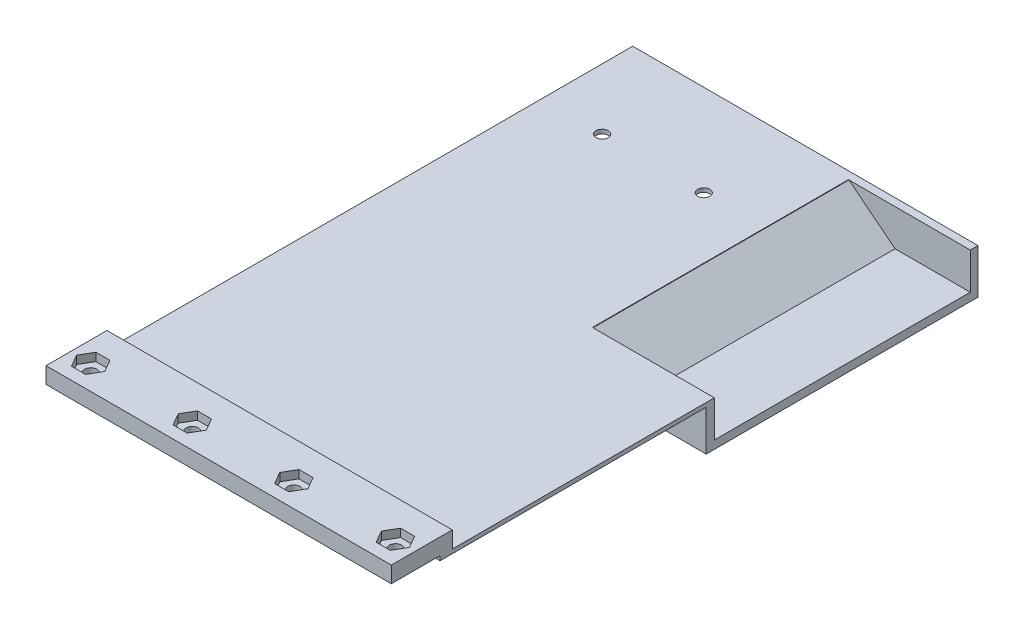
from build123d import *

# Parameters (mm, degrees)
SKETCH1_W           = 85
SKETCH1_H           = 12
SKETCH1_R           = 1.5
BOSS_EXTRUDE1_DEPTH = 2
SKETCH1_3_W         = 85
SKETCH1_3_H         = 12
BOSS_EXTRUDE2_DEPTH = 4
SKETCH2_W           = 85
SKETCH2_H           = 3
BOSS_EXTRUDE3_DEPTH = 5.1
BOSS_EXTRUDE4_DEPTH = 1
BOSS_EXTRUDE5_DEPTH = 10
SKETCH5_W           = 32
SKETCH5_H           = 67
BOSS_EXTRUDE6_DEPTH = 2
SKETCH6_W           = 32
SKETCH6_H           = 2
BOSS_EXTRUDE7_DEPTH = 11
BOSS_EXTRUDE9_DEPTH = 65
SKETCH9_W           = 100.016978449
SKETCH9_H           = 38.136204689
CUT_EXTRUDE1_DEPTH  = 0.1
SKETCH10_R          = 1.5
CUT_EXTRUDE2_DEPTH  = 6.1


with BuildPart() as part:
    # Sketch1 → Boss-Extrude1 (new body)
    with BuildSketch(Plane(origin=(0, 0, 0), x_dir=(1, 0, 0), z_dir=(0, 1, 0))):
        with Locations((42.5, 6)):
            Rectangle(SKETCH1_W, SKETCH1_H)
        Polygon((81.732050808, 3), (83.464101615, 6), (81.732050808, 9), (78.267949192, 9), (76.535898385, 6), (78.267949192, 3), align=None, mode=Mode.SUBTRACT)
        Polygon((56.732050808, 3), (58.464101615, 6), (56.732050808, 9), (53.267949192, 9), (51.535898385, 6), (53.267949192, 3), align=None, mode=Mode.SUBTRACT)
        Polygon((31.732050808, 3), (33.464101615, 6), (31.732050808, 9), (28.267949192, 9), (26.535898385, 6), (28.267949192, 3), align=None, mode=Mode.SUBTRACT)
        Polygon((6.732050808, 3), (8.464101615, 6), (6.732050808, 9), (3.267949192, 9), (1.535898385, 6), (3.267949192, 3), align=None, mode=Mode.SUBTRACT)
        Polygon((3.267949192, 3), (6.732050808, 3), (8.464101615, 6), (6.732050808, 9), (3.267949192, 9), (1.535898385, 6), align=None)
        with Locations((5, 6)):
            Circle(SKETCH1_R, mode=Mode.SUBTRACT)
        Polygon((28.267949192, 3), (31.732050808, 3), (33.464101615, 6), (31.732050808, 9), (28.267949192, 9), (26.535898385, 6), align=None)
        with Locations((30, 6)):
            Circle(SKETCH1_R, mode=Mode.SUBTRACT)
        Polygon((53.267949192, 3), (56.732050808, 3), (58.464101615, 6), (56.732050808, 9), (53.267949192, 9), (51.535898385, 6), align=None)
        with Locations((55, 6)):
            Circle(SKETCH1_R, mode=Mode.SUBTRACT)
        Polygon((78.267949192, 3), (81.732050808, 3), (83.464101615, 6), (81.732050808, 9), (78.267949192, 9), (76.535898385, 6), align=None)
        with Locations((80, 6)):
            Circle(SKETCH1_R, mode=Mode.SUBTRACT)
    extrude(amount=BOSS_EXTRUDE1_DEPTH)

    # Sketch1_3 → Boss-Extrude2 (add)
    with BuildSketch(Plane(origin=(0, 0, 0), x_dir=(1, 0, 0), z_dir=(0, 1, 0))):
        with Locations((42.5, 6)):
            Rectangle(SKETCH1_3_W, SKETCH1_3_H)
        Polygon((81.732050808, 3), (83.464101615, 6), (81.732050808, 9), (78.267949192, 9), (76.535898385, 6), (78.267949192, 3), align=None, mode=Mode.SUBTRACT)
        Polygon((56.732050808, 3), (58.464101615, 6), (56.732050808, 9), (53.267949192, 9), (51.535898385, 6), (53.267949192, 3), align=None, mode=Mode.SUBTRACT)
        Polygon((31.732050808, 3), (33.464101615, 6), (31.732050808, 9), (28.267949192, 9), (26.535898385, 6), (28.267949192, 3), align=None, mode=Mode.SUBTRACT)
        Polygon((6.732050808, 3), (8.464101615, 6), (6.732050808, 9), (3.267949192, 9), (1.535898385, 6), (3.267949192, 3), align=None, mode=Mode.SUBTRACT)
    extrude(amount=BOSS_EXTRUDE2_DEPTH)

    # Sketch2 → Boss-Extrude3 (add)
    with BuildSketch(Plane(origin=(0, 4, 0), x_dir=(1, 0, 0), z_dir=(0, 1, 0))):
        with Locations((42.5, 13.5)):
            Rectangle(SKETCH2_W, SKETCH2_H)
    extrude(amount=-BOSS_EXTRUDE3_DEPTH)

    # Sketch3 → Boss-Extrude4 (add)
    with BuildSketch(Plane.XZ.offset(1.1)):
        Polygon((85, -12), (0, -12), (0, -144.5), (55, -144.5), (55, -79.5), (85, -79.5), align=None)
    extrude(amount=-BOSS_EXTRUDE4_DEPTH)

    # Sketch4 → Boss-Extrude5 (add)
    with BuildSketch(Plane.XZ.offset(1.1)):
        Polygon((85, -79.5), (85, -77.5), (53, -77.5), (53, -144.5), (55, -144.5), (55, -79.5), align=None)
    extrude(amount=BOSS_EXTRUDE5_DEPTH)

    # Sketch5 → Boss-Extrude6 (add)
    with BuildSketch(Plane.XZ.offset(11.1)):
        with Locations((69, -111)):
            Rectangle(SKETCH5_W, SKETCH5_H)
    extrude(amount=-BOSS_EXTRUDE6_DEPTH)

    # Sketch6 → Boss-Extrude7 (add)
    with BuildSketch(Plane.XZ.offset(11.1)):
        with Locations((69, -143.5)):
            Rectangle(SKETCH6_W, SKETCH6_H)
    extrude(amount=-BOSS_EXTRUDE7_DEPTH)

    # Sketch8 → Boss-Extrude9 (add)
    with BuildSketch(Plane(origin=(0, 0, -144.5), x_dir=(-1, 0, 0), z_dir=(0, 0, -1))):
        Polygon((-55.130583843, -11.1), (-55.130583843, -0.1), (-69, -11.1), align=None)
    extrude(amount=-BOSS_EXTRUDE9_DEPTH)

    # Sketch9 → Cut-Extrude1 (cut)
    with BuildSketch(Plane(origin=(0, 0, -144.5), x_dir=(-1, 0, 0), z_dir=(0, 0, -1))):
        with Locations((-50.008489225, -19.168102345)):
            Rectangle(SKETCH9_W, SKETCH9_H)
    extrude(amount=-CUT_EXTRUDE1_DEPTH, mode=Mode.SUBTRACT)

    # Sketch10 → Cut-Extrude2 (cut, through all)
    with BuildSketch(Plane.XZ.offset(1.1)):
        with Locations((15, -121.9)):
            Circle(SKETCH10_R)
        with Locations((40, -121.9)):
            Circle(SKETCH10_R)
    extrude(amount=-CUT_EXTRUDE2_DEPTH, mode=Mode.SUBTRACT)


solid = part.part
